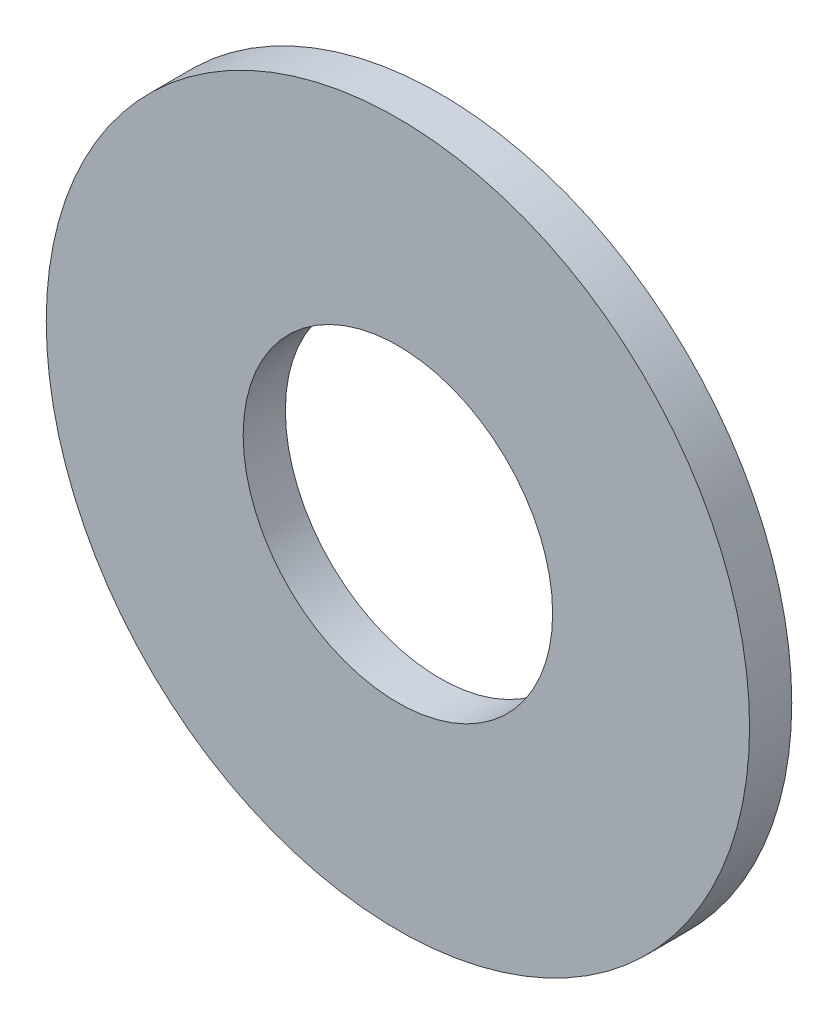
from build123d import *

# Parameters (mm, degrees)
SKETCH_1_R      = 2.5
SKETCH_1_R_2    = 1.1
EXTRUDE_1_DEPTH = 0.3


with BuildPart() as part:
    # Эскиз1 → Бобышка-Вытянуть1 (new body)
    with BuildSketch(Plane.XY):
        Circle(SKETCH_1_R)
        Circle(SKETCH_1_R_2, mode=Mode.SUBTRACT)
    extrude(amount=EXTRUDE_1_DEPTH)


solid = part.part
